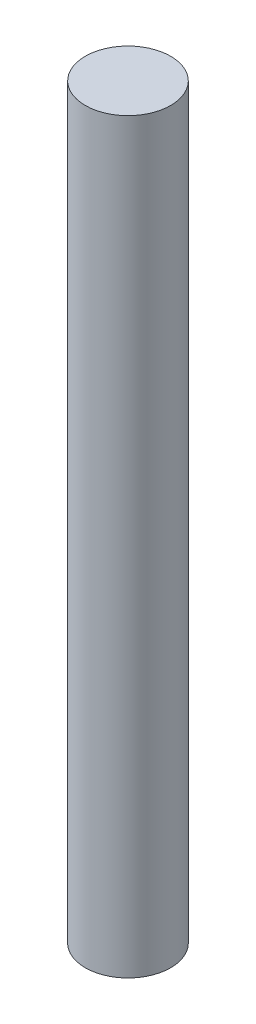
from build123d import *

# Parameters (mm, degrees)
SKETCH1_R           = 4
BOSS_EXTRUDE1_DEPTH = 70


with BuildPart() as part:
    # Sketch1 → Boss-Extrude1 (new body)
    with BuildSketch(Plane(origin=(0, 0, 0), x_dir=(1, 0, 0), z_dir=(0, 1, 0))):
        Circle(SKETCH1_R)
    extrude(amount=BOSS_EXTRUDE1_DEPTH)


solid = part.part
